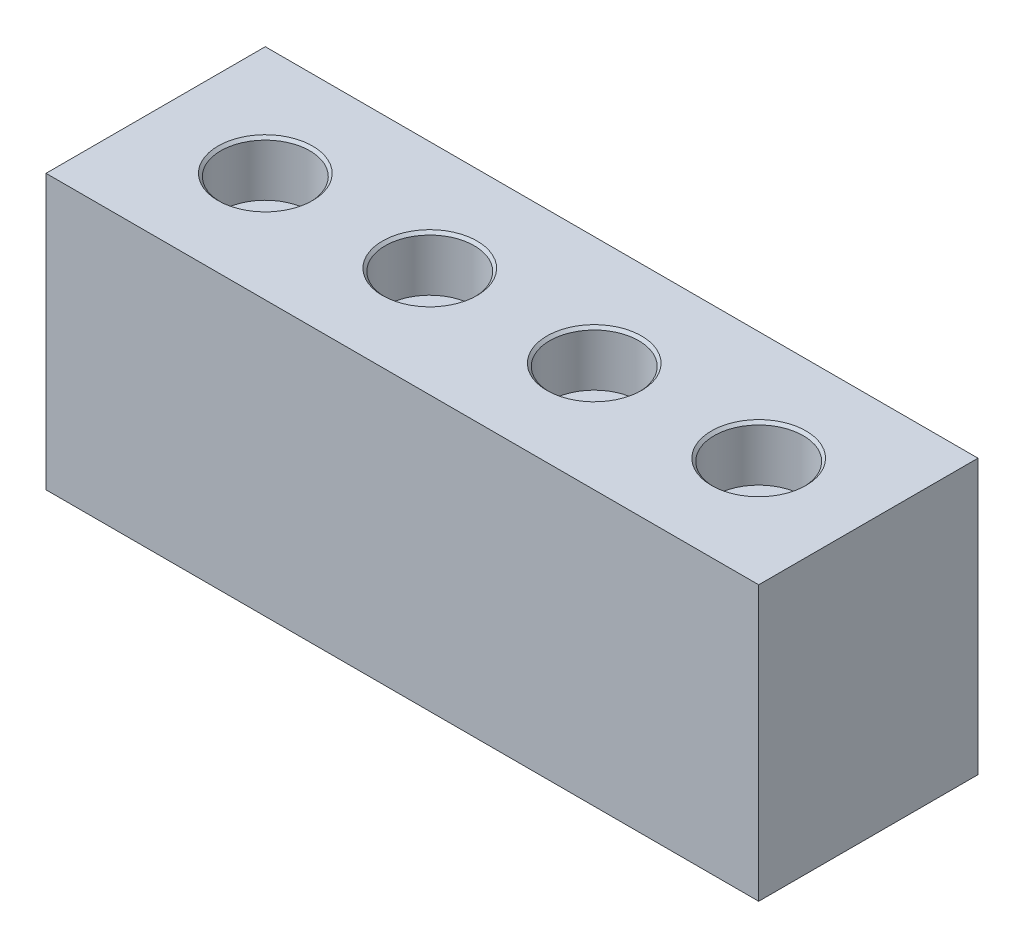
from build123d import *

# Parameters (mm, degrees)
SKETCH1_W           = 165.1
SKETCH1_H           = 63.5
BOSS_EXTRUDE1_DEPTH = 25.4
LPATTERN1_COUNT     = 4
LPATTERN1_PITCH     = 38.1


with BuildPart() as part:
    # Sketch1 → Boss-Extrude1 (new body, symmetric)
    with BuildSketch(Plane.XY):
        Rectangle(SKETCH1_W, SKETCH1_H)
    extrude(amount=BOSS_EXTRUDE1_DEPTH, both=True)

    # Sketch4 → CBORE for 1/2 Socket Head Cap Screw2 (revolve, cut)
    with BuildSketch(Plane(origin=(-57.15, 31.75, 0), x_dir=(0, 0, 1), z_dir=(1, 0, 0))):
        Polygon((0, 0), (0, 54.853549943), (6.74624, 50.8), (6.74624, 12.7), (10.31875, 12.7), (10.31875, 0.635), (10.95375, 0), align=None)
    cbore_for_1_2_socket_head_cap_screw2 = revolve(axis=Axis((-57.15, 38.1, 0), (0, -1, 0)), mode=Mode.SUBTRACT)

    # LPattern1: CBORE for 1/2 Socket Head Cap Screw2 ×4
    with Locations(*[(i * LPATTERN1_PITCH, 0, 0) for i in range(1, LPATTERN1_COUNT)]):
        add(cbore_for_1_2_socket_head_cap_screw2, mode=Mode.SUBTRACT)


solid = part.part
